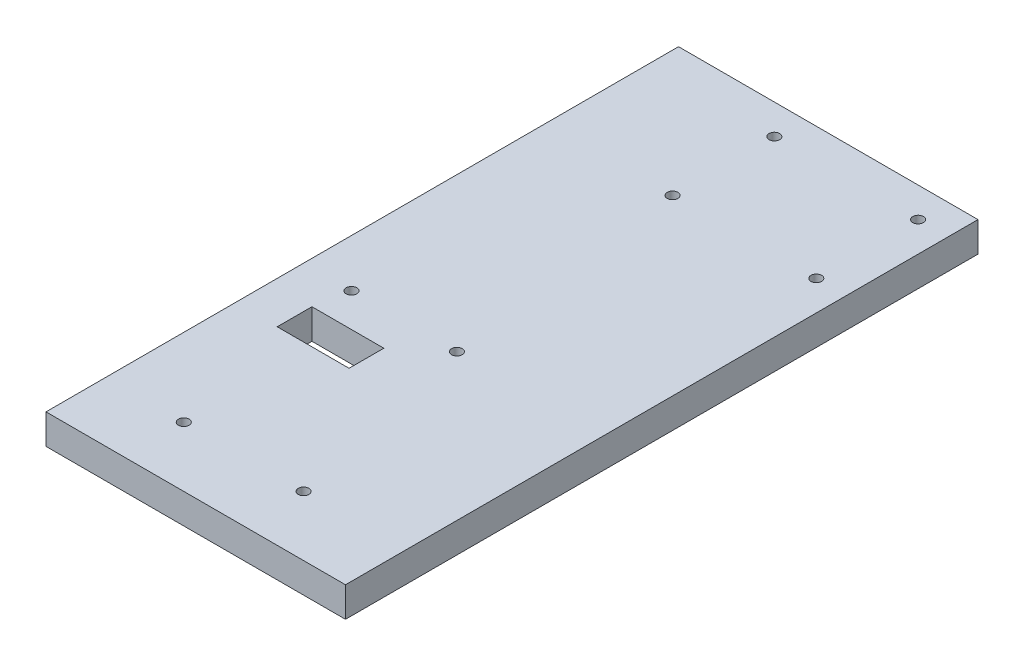
from build123d import *

# Parameters (mm, degrees)
SKETCH1_W             = 63.5
SKETCH1_H             = 134.112
BOSS_EXTRUDE1_DEPTH   = 6.35
SKETCH4_W             = 15.24
SKETCH4_H             = 7.366
CUT_EXTRUDE3_DEPTH    = 7.35
F_4_40_TAPPED_HOLE1_D = 2.2606
F_4_40_TAPPED_HOLE2_D = 2.2606
F_4_40_TAPPED_HOLE3_D = 2.2606


with BuildPart() as part:
    # Sketch1 → Boss-Extrude1 (new body)
    with BuildSketch(Plane(origin=(0, 0, 0), x_dir=(1, 0, 0), z_dir=(0, 1, 0))):
        with Locations((31.75, 67.056)):
            Rectangle(SKETCH1_W, SKETCH1_H)
    extrude(amount=BOSS_EXTRUDE1_DEPTH)

    # Sketch4 → Cut-Extrude3 (cut, through all)
    with BuildSketch(Plane(origin=(0, 6.35, 0), x_dir=(1, 0, 0), z_dir=(0, 1, 0))):
        with Locations((16.51, 43.815)):
            Rectangle(SKETCH4_W, SKETCH4_H)
    extrude(amount=-CUT_EXTRUDE3_DEPTH, mode=Mode.SUBTRACT)

    # #4-40 Tapped Hole1 (through all)
    with Locations(Plane(origin=(0, 6.35, 0), x_dir=(1, 0, 0), z_dir=(0, 1, 0))):
        with Locations((57.15, 127.762), (57.15, 106.172), (26.67, 106.172), (26.67, 127.762)):
            Hole(F_4_40_TAPPED_HOLE1_D / 2)

    # #4-40 Tapped Hole2 (through all)
    with Locations(Plane(origin=(0, 6.35, 0), x_dir=(1, 0, 0), z_dir=(0, 1, 0))):
        with Locations((32.512, 54.61), (10.16, 54.61)):
            Hole(F_4_40_TAPPED_HOLE2_D / 2)

    # #4-40 Tapped Hole3 (through all)
    with Locations(Plane(origin=(0, 6.35, 0), x_dir=(1, 0, 0), z_dir=(0, 1, 0))):
        with Locations((41.91, 12.7), (16.51, 12.7)):
            Hole(F_4_40_TAPPED_HOLE3_D / 2)


solid = part.part
